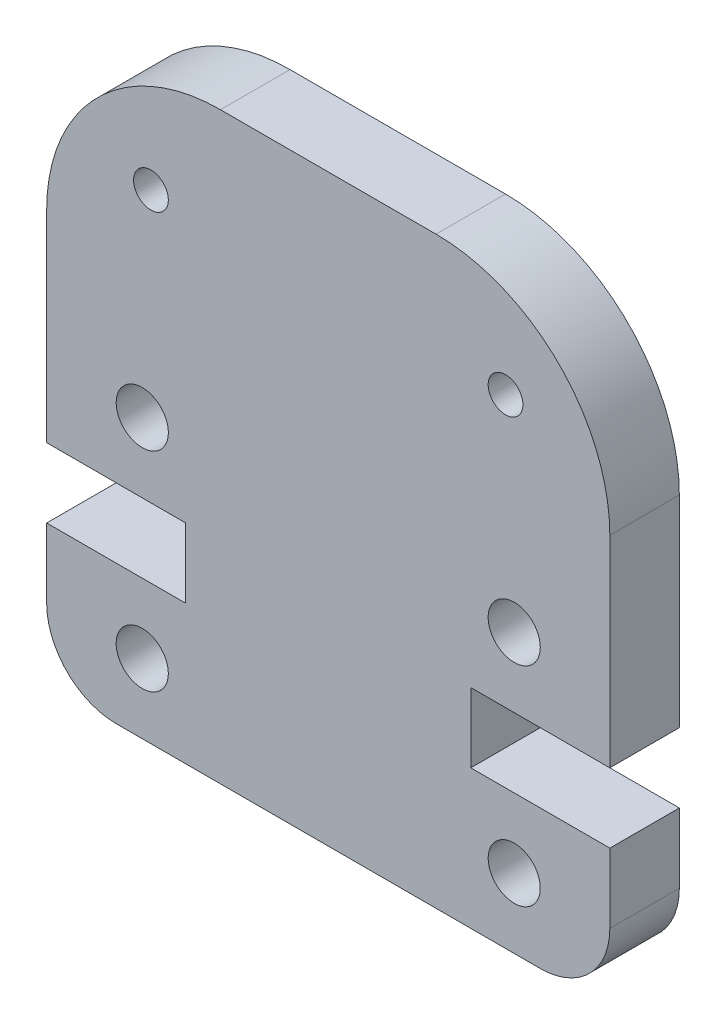
from build123d import *

# Parameters (mm, degrees)
SKETCH1_R           = 0.75
SKETCH1_R_2         = 0.5
BOSS_EXTRUDE1_DEPTH = 2


with BuildPart() as part:
    # Sketch1 → Boss-Extrude1 (new body)
    with BuildSketch(Plane.XY):
        with BuildLine():
            Line((0, 6), (0, 11.795))
            ThreePointArc((0, 11.795), (1.464466094, 15.330533906), (5, 16.795))
            Line((5, 16.795), (11.2, 16.795))
            ThreePointArc((11.2, 16.795), (14.735533906, 15.330533906), (16.2, 11.795))
            Line((16.2, 11.795), (16.2, 6))
            Line((16.2, 6), (12.2, 6))
            Line((12.2, 6), (12.2, 4))
            Line((12.2, 4), (16.2, 4))
            Line((16.2, 4), (16.2, 2))
            ThreePointArc((16.2, 2), (15.614213562, 0.585786438), (14.2, 0))
            Line((14.2, 0), (2, 0))
            ThreePointArc((2, 0), (0.585786438, 0.585786438), (0, 2))
            Line((0, 2), (0, 4))
            Line((0, 4), (4, 4))
            Line((4, 4), (4, 6))
            Line((4, 6), (0, 6))
        make_face()
        with Locations((13.45, 2)):
            Circle(SKETCH1_R, mode=Mode.SUBTRACT)
        with Locations((13.45, 8)):
            Circle(SKETCH1_R, mode=Mode.SUBTRACT)
        with Locations((3, 13.795)):
            Circle(SKETCH1_R_2, mode=Mode.SUBTRACT)
        with Locations((13.2, 13.795)):
            Circle(SKETCH1_R_2, mode=Mode.SUBTRACT)
        with Locations((2.75, 8)):
            Circle(SKETCH1_R, mode=Mode.SUBTRACT)
        with Locations((2.75, 2)):
            Circle(SKETCH1_R, mode=Mode.SUBTRACT)
    extrude(amount=BOSS_EXTRUDE1_DEPTH)


solid = part.part
